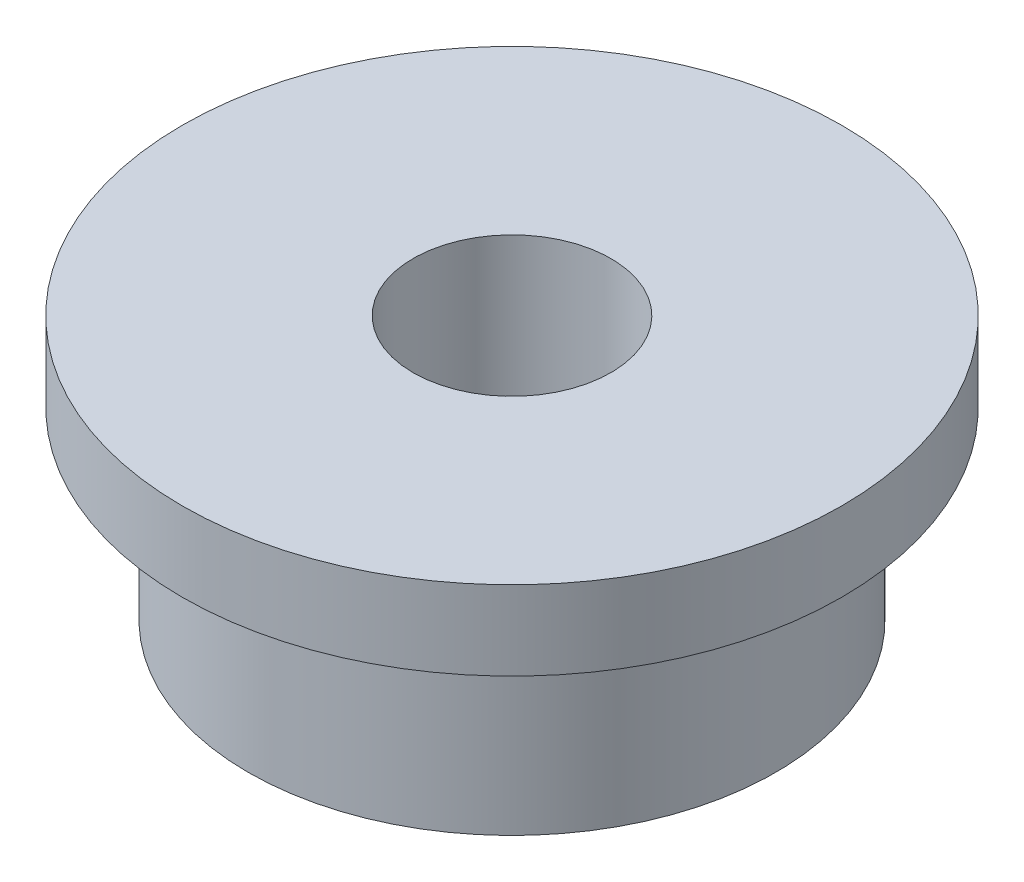
from build123d import *

# Parameters (mm, degrees)
SKETCH1_R           = 2
SKETCH1_R_2         = 0.75
BOSS_EXTRUDE1_DEPTH = 2
SKETCH2_R           = 2.5
SKETCH2_R_2         = 2
BOSS_EXTRUDE2_DEPTH = 0.6


with BuildPart() as part:
    # Sketch1 → Boss-Extrude1 (new body)
    with BuildSketch(Plane(origin=(0, 0, 0), x_dir=(1, 0, 0), z_dir=(0, 1, 0))):
        Circle(SKETCH1_R)
        Circle(SKETCH1_R_2, mode=Mode.SUBTRACT)
    extrude(amount=BOSS_EXTRUDE1_DEPTH)

    # Sketch2 → Boss-Extrude2 (add)
    with BuildSketch(Plane(origin=(0, 2, 0), x_dir=(1, 0, 0), z_dir=(0, 1, 0))):
        Circle(SKETCH2_R)
        Circle(SKETCH2_R_2, mode=Mode.SUBTRACT)
    extrude(amount=-BOSS_EXTRUDE2_DEPTH)


solid = part.part
